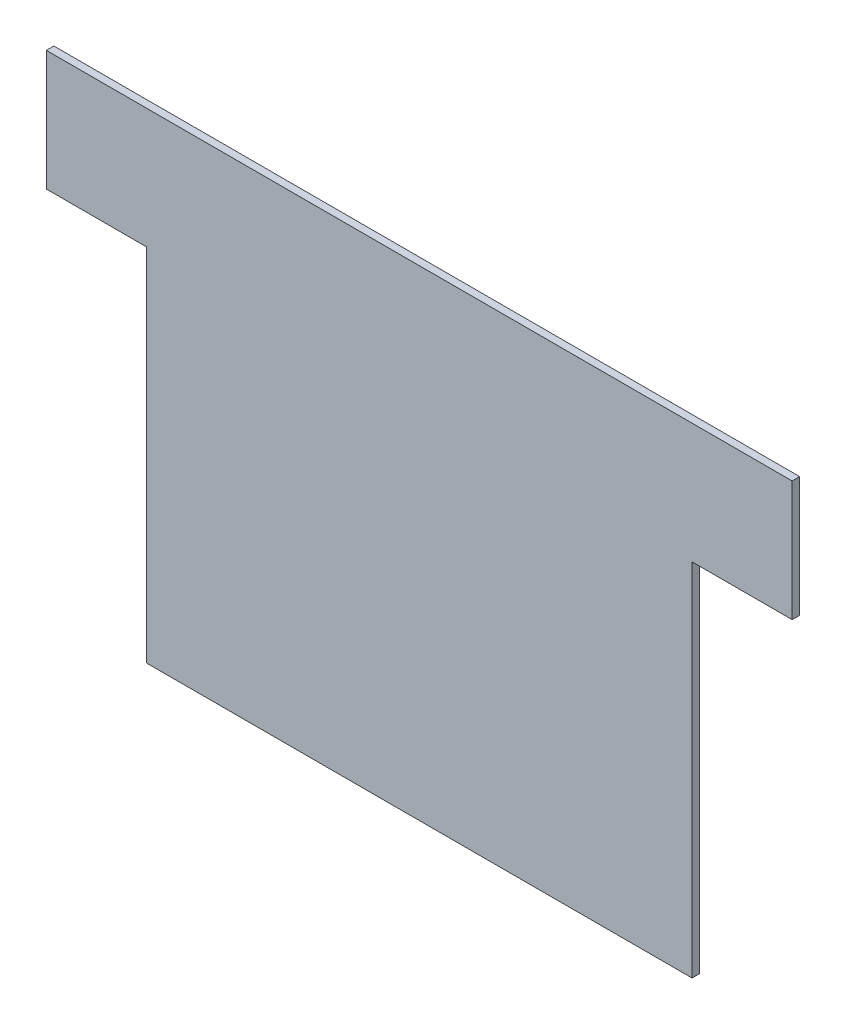
from build123d import *

# Parameters (mm, degrees)
BOSS_EXTRUDE1_DEPTH = 4.7625


with BuildPart() as part:
    # Sketch3 → Boss-Extrude1 (new body)
    with BuildSketch(Plane.XY):
        Polygon((346.075, 228.6), (409.575, 228.6), (409.575, 304.8), (-63.5, 304.8), (-63.5, 228.6), (0, 228.6), (0, 0), (346.075, 0), align=None)
    extrude(amount=BOSS_EXTRUDE1_DEPTH)


solid = part.part
